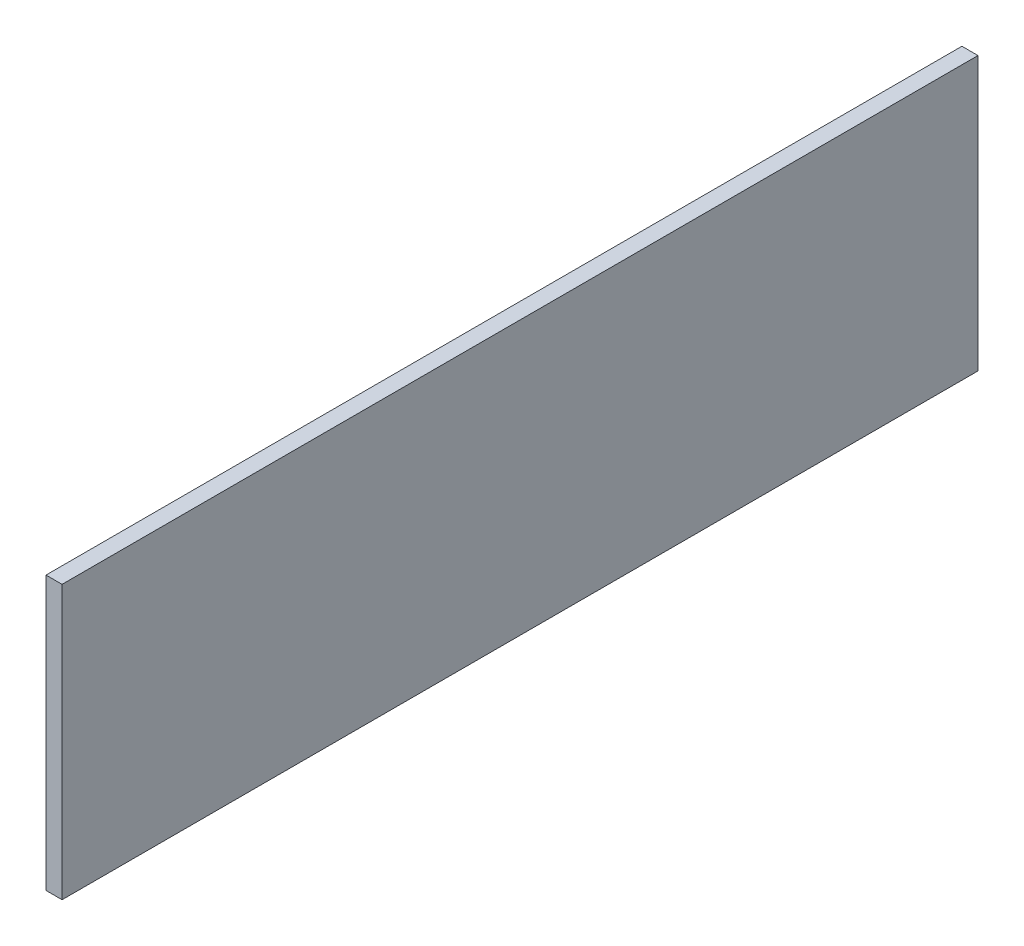
from build123d import *

# Parameters (mm, degrees)
SKETCH1_W           = 144.78
SKETCH1_H           = 43.18
BOSS_EXTRUDE1_DEPTH = 2.54


with BuildPart() as part:
    # Sketch1 → Boss-Extrude1 (new body)
    with BuildSketch(Plane(origin=(0, 0, 0), x_dir=(0, 0, -1), z_dir=(1, 0, 0))):
        with Locations((72.39, 21.59)):
            Rectangle(SKETCH1_W, SKETCH1_H)
    extrude(amount=BOSS_EXTRUDE1_DEPTH)


solid = part.part
